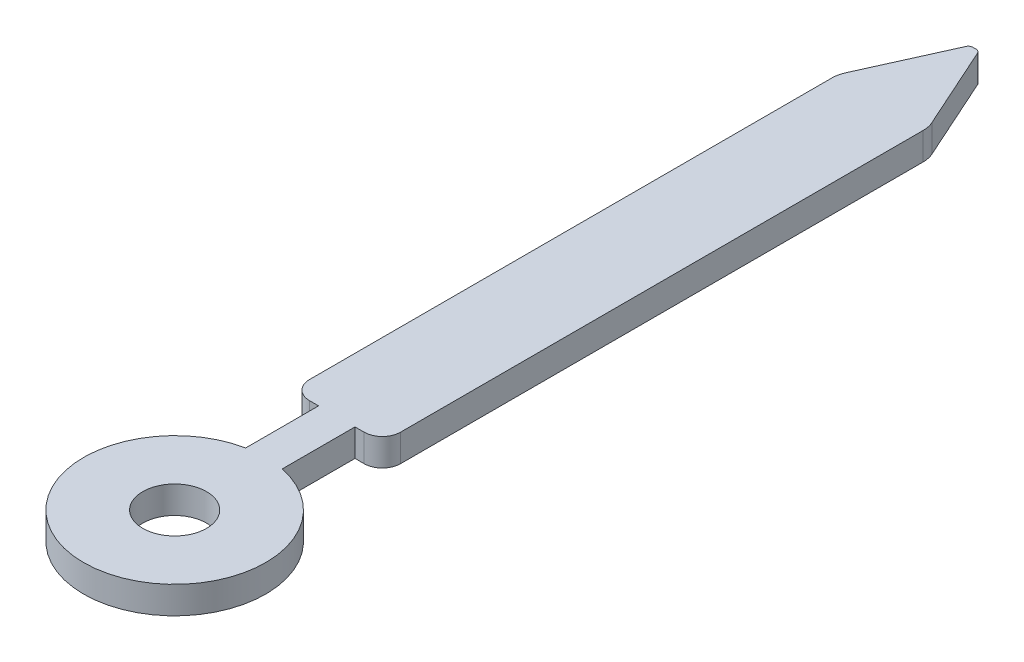
from build123d import *

# Parameters (mm, degrees)
SKETCH1_R           = 0.35
BOSS_EXTRUDE1_DEPTH = 0.3


with BuildPart() as part:
    # Sketch1 → Boss-Extrude1 (new body)
    with BuildSketch(Plane(origin=(0, 0, 0), x_dir=(1, 0, 0), z_dir=(0, 1, 0))):
        with BuildLine():
            Line((0.063001459, 6.971107869), (0.473576452, 6.058718997))
            ThreePointArc((0.473576452, 6.058718997), (0.493319736, 5.998566184), (0.5, 5.935609593))
            Line((0.5, 5.935609593), (0.5, 0.2))
            ThreePointArc((0.5, 0.2), (0.441421356, 0.058578644), (0.3, 0))
            Line((0.3, 0), (0.2, 0))
            Line((0.2, 0), (0.2, -0.8))
            ThreePointArc((0.2, -0.8), (0, -2.779795897), (-0.2, -0.8))
            Line((-0.2, -0.8), (-0.2, 0))
            Line((-0.2, 0), (-0.3, 0))
            ThreePointArc((-0.3, 0), (-0.441421356, 0.058578644), (-0.5, 0.2))
            Line((-0.5, 0.2), (-0.5, 5.935609593))
            ThreePointArc((-0.5, 5.935609593), (-0.493319736, 5.998566184), (-0.473576452, 6.058718997))
            Line((-0.473576452, 6.058718997), (-0.063001459, 6.971107869))
            ThreePointArc((-0.063001459, 6.971107869), (-0.044922891, 6.992147816), (-0.018317305, 7))
            Line((-0.018317305, 7), (0.018317305, 7))
            ThreePointArc((0.018317305, 7), (0.044922891, 6.992147816), (0.063001459, 6.971107869))
        make_face()
        with Locations((0, -1.779795897)):
            Circle(SKETCH1_R, mode=Mode.SUBTRACT)
    extrude(amount=BOSS_EXTRUDE1_DEPTH)


solid = part.part
